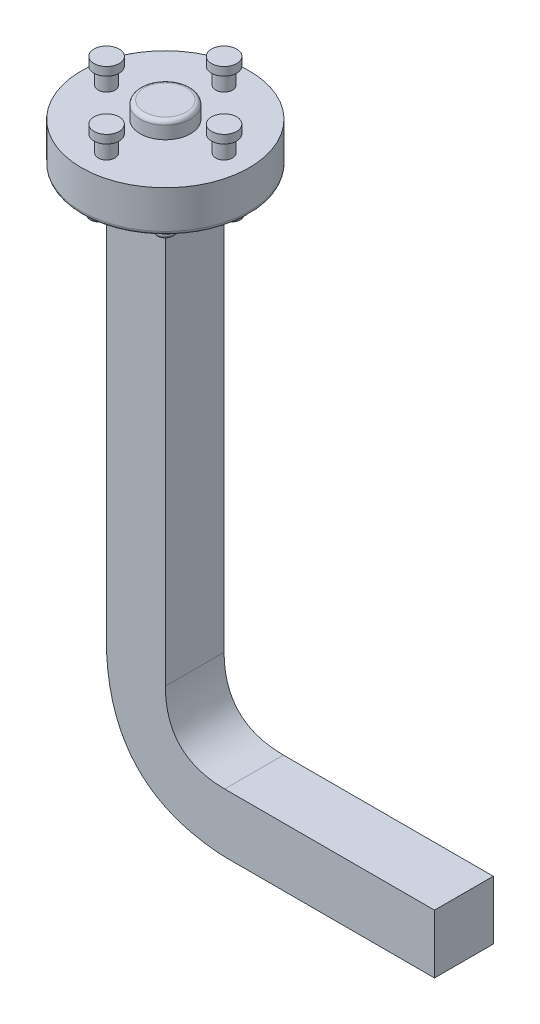
from build123d import *

# Parameters (mm, degrees)
SKETCH1_R                = 100
BOSS_EXTRUDE1_DEPTH      = 50
SKETCH2_R                = 30
SKETCH2_R_2              = 10
BOSS_EXTRUDE2_DEPTH      = 20
F_3DSKETCH1_R            = 15
BOSS_EXTRUDE3_DEPTH      = 10
FILLET1_R                = 5
SKETCH3_R                = 10
BOSS_EXTRUDE4_DEPTH      = 10
FILLET2_R                = 5
FILLET3_R                = 2.5
BOSS_EXTRUDE7_DEPTH      = 35
BOSS_EXTRUDE7_DEPTH_BACK = 35
SCALE1_SCALE             = 0.5


with BuildPart() as part:
    # Sketch1 → Boss-Extrude1 (new body)
    with BuildSketch(Plane(origin=(0, 0, 0), x_dir=(1, 0, 0), z_dir=(0, 1, 0))):
        Circle(SKETCH1_R)
    extrude(amount=BOSS_EXTRUDE1_DEPTH)

    # Sketch2 → Boss-Extrude2 (add)
    with BuildSketch(Plane(origin=(0, 50, 0), x_dir=(1, 0, 0), z_dir=(0, 1, 0))):
        Circle(SKETCH2_R)
        with Locations((0, 70)):
            Circle(SKETCH2_R_2)
        with Locations((70, 0)):
            Circle(SKETCH2_R_2)
        with Locations((0, -70)):
            Circle(SKETCH2_R_2)
        with Locations((-70, 0)):
            Circle(SKETCH2_R_2)
    extrude(amount=BOSS_EXTRUDE2_DEPTH)

    # 3DSketch1 → Boss-Extrude3 (add)
    with BuildSketch(Plane(origin=(-70, 70, 0), x_dir=(1, 0, 0), z_dir=(0, 1, 0))):
        Circle(F_3DSKETCH1_R)
        with Locations((140, 0)):
            Circle(F_3DSKETCH1_R)
        with Locations((70, 70)):
            Circle(F_3DSKETCH1_R)
        with Locations((70, -70)):
            Circle(F_3DSKETCH1_R)
    extrude(amount=BOSS_EXTRUDE3_DEPTH)

    # Fillet1
    fillet1_edges = [part.edges().sort_by_distance(p)[0] for p in [
        (-30, 70, 0),
    ]]
    fillet(fillet1_edges, radius=FILLET1_R)

    # Sketch3 → Boss-Extrude4 (add)
    with BuildSketch(Plane(origin=(0, 0, 0), x_dir=(-1, 0, 0), z_dir=(0, -1, 0))):
        with Locations((0, 80)):
            Circle(SKETCH3_R)
        with Locations((56.568542495, 56.568542495)):
            Circle(SKETCH3_R)
        with Locations((80, 0)):
            Circle(SKETCH3_R)
        with Locations((56.568542495, -56.568542495)):
            Circle(SKETCH3_R)
        with Locations((0, -80)):
            Circle(SKETCH3_R)
        with Locations((-56.568542495, -56.568542495)):
            Circle(SKETCH3_R)
        with Locations((-80, 0)):
            Circle(SKETCH3_R)
        with Locations((-56.568542495, 56.568542495)):
            Circle(SKETCH3_R)
    extrude(amount=BOSS_EXTRUDE4_DEPTH)

    # Fillet2
    fillet2_edges = [part.edges().sort_by_distance(p)[0] for p in [
        (-100, 0, 0),
    ]]
    fillet(fillet2_edges, radius=FILLET2_R)

    # Fillet3
    fillet3_edges = [part.edges().sort_by_distance(p)[0] for p in [
        (-70, -10, 0),
        (-46.568542495, -10, 56.568542495),
        (10, -10, 80),
        (90, -10, 0),
        (-46.568542495, -10, -56.568542495),
        (10, -10, -80),
        (66.568542495, -10, -56.568542495),
        (10, 0, -80),
        (-46.568542495, 0, -56.568542495),
        (-70, 0, 0),
        (-46.568542495, 0, 56.568542495),
        (10, 0, 80),
        (66.568542495, 0, 56.568542495),
        (90, 0, 0),
        (66.568542495, 0, -56.568542495),
        (66.568542495, -10, 56.568542495),
    ]]
    fillet(fillet3_edges, radius=FILLET3_R)

    # Sketch8 → Boss-Extrude7 (add, two sides: drawn at the far end of the back side and taken through both)
    with BuildSketch(Plane.XY.offset(-BOSS_EXTRUDE7_DEPTH_BACK)):
        with BuildLine():
            Line((0, 0), (-35, 0))
            Line((-35, 0), (-35, -500))
            add(Edge.make_bspline(
                [(-35, -500), (-28.639610307, -634.350288425), (105.710678119, -640.710678119)],
                knots=[0, 0, 0, 1, 1, 1], degree=2))
            Line((105.710678119, -640.710678119), (355.710678119, -640.710678119))
            Line((355.710678119, -640.710678119), (355.710678119, -570.710678119))
            Line((355.710678119, -570.710678119), (105.710678119, -570.710678119))
            add(Edge.make_bspline(
                [(35, -500), (35.355339059, -570.355339059), (105.710678119, -570.710678119)],
                knots=[0, 0, 0, 1, 1, 1], degree=2))
            Line((35, -500), (35, 0))
            Line((35, 0), (0, 0))
        make_face()
    extrude(amount=BOSS_EXTRUDE7_DEPTH + BOSS_EXTRUDE7_DEPTH_BACK)


with BuildPart() as part_1:
    # Scale1: scaled about (50.19221528, -286.832744654, 0)
    add(part.part.scale(SCALE1_SCALE).moved(Location((25.09610764, -143.416372327, 0))))


solid = part_1.part
